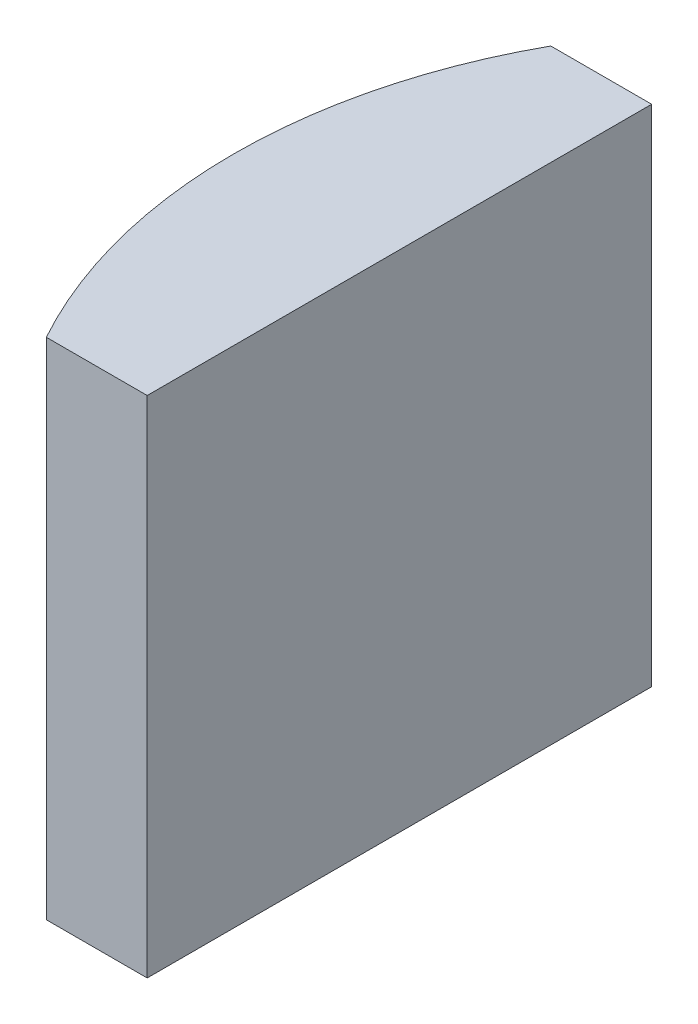
from build123d import *

# Parameters (mm, degrees)
EXTRUDE_1_DEPTH = 10


with BuildPart() as part:
    # 草图1 → 凸台-拉伸1 (new body)
    with BuildSketch(Plane(origin=(0, 0, 0), x_dir=(1, 0, 0), z_dir=(0, 1, 0))):
        with BuildLine():
            Line((-4.684093204, 5), (-2.684795665, 5))
            Line((-2.684795665, 5), (-2.684795665, -5))
            Line((-2.684795665, -5), (-4.684093204, -5))
            ThreePointArc((-4.684093204, -5), (-5.974795665, 0), (-4.684093204, 5))
        make_face()
    extrude(amount=EXTRUDE_1_DEPTH)


solid = part.part
